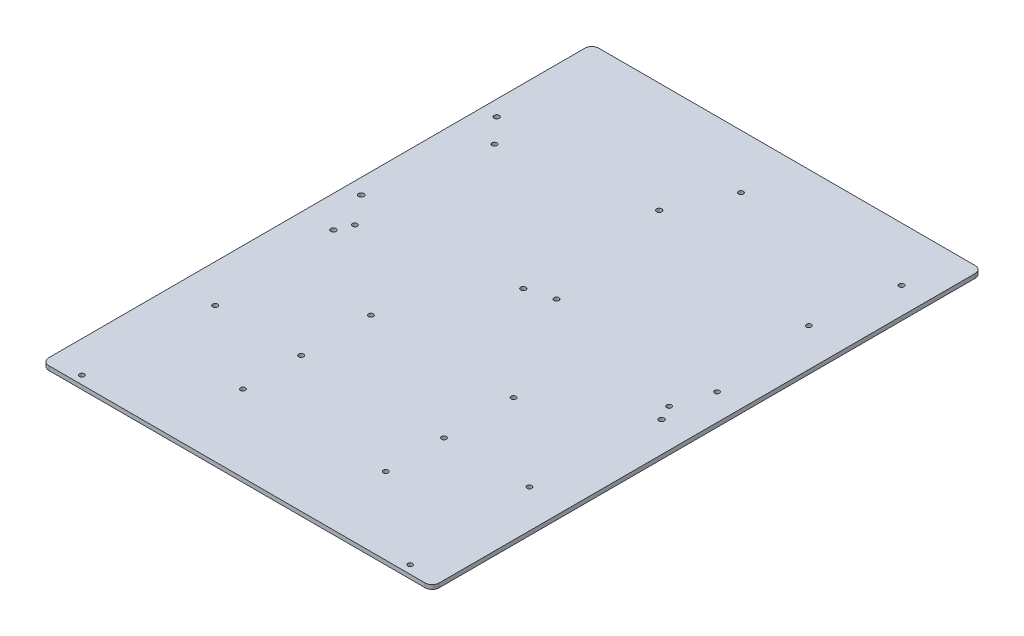
from build123d import *

# Parameters (mm, degrees)
SKETCH1_W           = 279.4
SKETCH1_H           = 393.7
BOSS_EXTRUDE1_DEPTH = 3
SKETCH2_R           = 1.71604989
SKETCH2_R_2         = 1.75
SKETCH2_R_3         = 1.7
SKETCH2_R_4         = 1.870862721
SKETCH2_R_5         = 1.883317569
SKETCH2_R_6         = 1.83699597
SKETCH2_R_7         = 1.924205911
SKETCH2_R_8         = 1.847035123
SKETCH2_R_9         = 1.86155666
CUT_EXTRUDE1_DEPTH  = 4
SKETCH3_R           = 1.75
CUT_EXTRUDE2_DEPTH  = 4
SKETCH4_R           = 1.75
CUT_EXTRUDE3_DEPTH  = 4
FILLET1_R           = 5


with BuildPart() as part:
    # Sketch1 → Boss-Extrude1 (new body)
    with BuildSketch(Plane(origin=(0, 0, 0), x_dir=(1, 0, 0), z_dir=(0, 1, 0))):
        Rectangle(SKETCH1_W, SKETCH1_H)
    extrude(amount=BOSS_EXTRUDE1_DEPTH)

    # Sketch2 → Cut-Extrude1 (cut, through all)
    with BuildSketch(Plane(origin=(0, 3, 0), x_dir=(1, 0, 0), z_dir=(0, 1, 0))):
        with Locations((-117.02025572, -190.887260588)):
            Circle(SKETCH2_R)
        with Locations((5.710036522, 158.14420085)):
            Circle(SKETCH2_R_2)
        with Locations((120.710036522, 158.14420085)):
            Circle(SKETCH2_R_2)
        with Locations((120.710036522, 26.14420085)):
            Circle(SKETCH2_R_2)
        with Locations((5.710036522, 26.14420085)):
            Circle(SKETCH2_R_2)
        with Locations((117.97974428, -190.887260588)):
            Circle(SKETCH2_R_3)
        with Locations((-117.02025572, -10.887260588)):
            Circle(SKETCH2_R_4)
        with Locations((117.97974428, -10.887260588)):
            Circle(SKETCH2_R_5)
        with Locations((-128.708296928, 117.786916863)):
            Circle(SKETCH2_R_6)
        with Locations((-128.708296928, 20.786916863)):
            Circle(SKETCH2_R_7)
        with Locations((-12.708296928, 20.786916863)):
            Circle(SKETCH2_R_8)
        with Locations((-12.57462446, 117.92058933)):
            Circle(SKETCH2_R_9)
    extrude(amount=-CUT_EXTRUDE1_DEPTH, mode=Mode.SUBTRACT)

    # Sketch3 → Cut-Extrude2 (cut, through all)
    with BuildSketch(Plane(origin=(0, 3, 0), x_dir=(1, 0, 0), z_dir=(0, 1, 0))):
        with Locations((-112.5, -100)):
            Circle(SKETCH3_R)
        with Locations((112.5, -100)):
            Circle(SKETCH3_R)
        with Locations((-112.5, 100)):
            Circle(SKETCH3_R)
        with Locations((112.5, 100)):
            Circle(SKETCH3_R)
        with Locations((-112.5, 0)):
            Circle(SKETCH3_R)
        with Locations((112.5, 0)):
            Circle(SKETCH3_R)
    extrude(amount=-CUT_EXTRUDE2_DEPTH, mode=Mode.SUBTRACT)

    # Sketch4 → Cut-Extrude3 (cut, through all)
    with BuildSketch(Plane(origin=(0, 3, 0), x_dir=(1, 0, 0), z_dir=(0, 1, 0))):
        with Locations((-50.759432207, -100.193826828)):
            Circle(SKETCH4_R)
        with Locations((51.456036179, -100.193826828)):
            Circle(SKETCH4_R)
        with Locations((-50.759432207, -50.297176383)):
            Circle(SKETCH4_R)
        with Locations((51.456036179, -50.297176383)):
            Circle(SKETCH4_R)
        with Locations((-50.759432207, -141.855107781)):
            Circle(SKETCH4_R)
        with Locations((51.456036179, -141.855107781)):
            Circle(SKETCH4_R)
    extrude(amount=-CUT_EXTRUDE3_DEPTH, mode=Mode.SUBTRACT)

    # Fillet1
    fillet1_edges = [part.edges().sort_by_distance(p)[0] for p in [
        (139.7, 1.5, 196.85),
        (-139.7, 1.5, 196.85),
        (-139.7, 1.5, -196.85),
        (139.7, 1.5, -196.85),
    ]]
    fillet(fillet1_edges, radius=FILLET1_R)


solid = part.part
